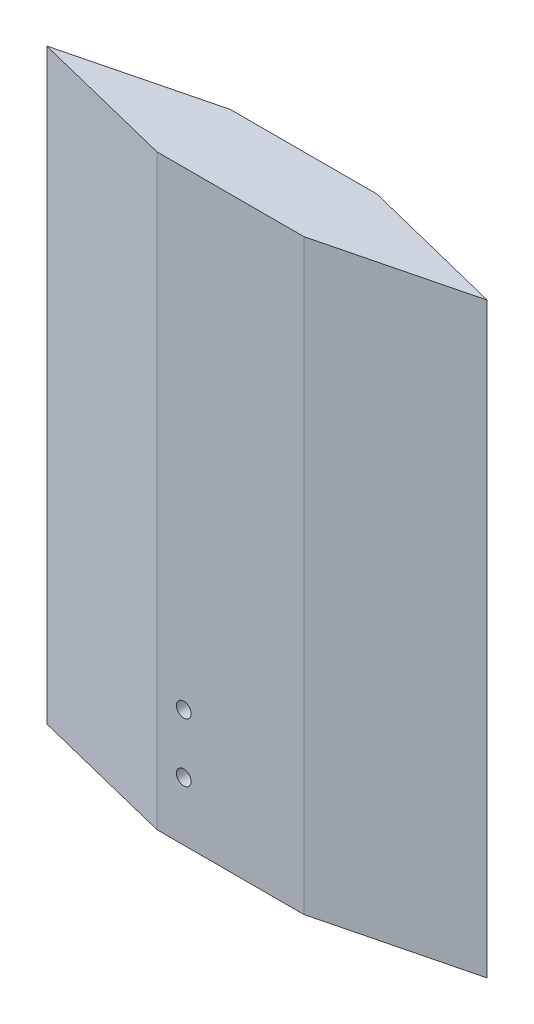
from build123d import *

# Parameters (mm, degrees)
BOSS_EXTRUDE1_DEPTH = 50.8
CUT_EXTRUDE1_DEPTH  = 16.51
SKETCH3_R           = 0.635
CUT_EXTRUDE2_DEPTH  = 3.175


with BuildPart() as part:
    # Sketch1 → Boss-Extrude1 (new body)
    with BuildSketch(Plane(origin=(0, 0, 0), x_dir=(1, 0, 0), z_dir=(0, 1, 0))):
        Polygon((0, 6.35), (-12.7, 3.1623), (0, 0), (12.7, 0), (25.4, 3.175), (12.7, 6.35), align=None)
    extrude(amount=BOSS_EXTRUDE1_DEPTH)

    # Sketch2 → Cut-Extrude1 (cut)
    with BuildSketch(Plane.XZ):
        with BuildLine():
            Line((3.175, -2.54), (3.175, -3.81))
            Line((3.175, -3.81), (1.454967783, -3.81))
            ThreePointArc((1.454967783, -3.81), (-1.5875, -3.175), (1.454967783, -2.54))
            Line((1.454967783, -2.54), (3.175, -2.54))
        make_face()
    extrude(amount=-CUT_EXTRUDE1_DEPTH, mode=Mode.SUBTRACT)

    # Sketch3 → Cut-Extrude2 (cut)
    with BuildSketch(Plane.XY):
        with Locations((2.31521, 5.08)):
            Circle(SKETCH3_R)
        with Locations((2.31521, 10.16)):
            Circle(SKETCH3_R)
    extrude(amount=-CUT_EXTRUDE2_DEPTH, mode=Mode.SUBTRACT)


solid = part.part
